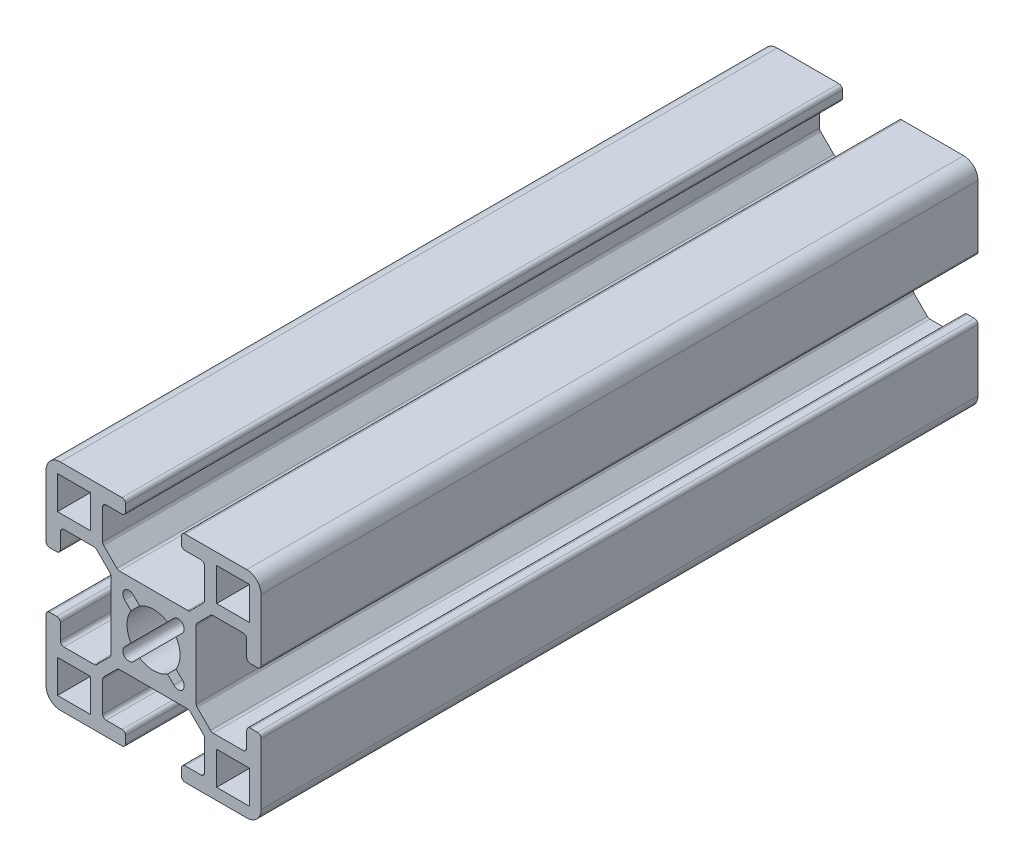
from build123d import *

# Parameters (mm, degrees)
SKETCH1_W           = 4.6
SKETCH1_H           = 4.6
BOSS_EXTRUDE1_DEPTH = 50


with BuildPart() as part:
    # Sketch1 → Boss-Extrude1 (new body, symmetric)
    with BuildSketch(Plane.XY):
        with BuildLine():
            Line((15, -13), (15, -4.4))
            ThreePointArc((15, -4.4), (14.853553391, -4.046446609), (14.5, -3.9))
            Line((14.5, -3.9), (13.5, -3.9))
            ThreePointArc((13.5, -3.9), (13.146446609, -4.046446609), (13, -4.4))
            Line((13, -4.4), (13, -6.6))
            ThreePointArc((13, -6.6), (12.853553391, -6.953553391), (12.5, -7.1))
            Line((12.5, -7.1), (8.297056275, -7.1))
            ThreePointArc((8.297056275, -7.1), (8.105714559, -7.061939766), (7.943502884, -6.953553391))
            Line((7.943502884, -6.953553391), (6.096446609, -5.106497116))
            ThreePointArc((6.096446609, -5.106497116), (5.988060234, -4.944285441), (5.95, -4.752943725))
            Line((5.95, -4.752943725), (5.95, 4.752943725))
            ThreePointArc((5.95, 4.752943725), (5.988060234, 4.944285441), (6.096446609, 5.106497116))
            Line((6.096446609, 5.106497116), (7.943502884, 6.953553391))
            ThreePointArc((7.943502884, 6.953553391), (8.105714559, 7.061939766), (8.297056275, 7.1))
            Line((8.297056275, 7.1), (12.5, 7.1))
            ThreePointArc((12.5, 7.1), (12.853553391, 6.953553391), (13, 6.6))
            Line((13, 6.6), (13, 4.4))
            ThreePointArc((13, 4.4), (13.146446609, 4.046446609), (13.5, 3.9))
            Line((13.5, 3.9), (14.5, 3.9))
            ThreePointArc((14.5, 3.9), (14.853553391, 4.046446609), (15, 4.4))
            Line((15, 4.4), (15, 13))
            ThreePointArc((15, 13), (14.414213562, 14.414213562), (13, 15))
            Line((13, 15), (4.4, 15))
            ThreePointArc((4.4, 15), (4.046446609, 14.853553391), (3.9, 14.5))
            Line((3.9, 14.5), (3.9, 13.5))
            ThreePointArc((3.9, 13.5), (4.046446609, 13.146446609), (4.4, 13))
            Line((4.4, 13), (6.6, 13))
            ThreePointArc((6.6, 13), (6.953553391, 12.853553391), (7.1, 12.5))
            Line((7.1, 12.5), (7.1, 8.297056275))
            ThreePointArc((7.1, 8.297056275), (7.061939766, 8.105714559), (6.953553391, 7.943502884))
            Line((6.953553391, 7.943502884), (5.106497116, 6.096446609))
            ThreePointArc((5.106497116, 6.096446609), (4.944285441, 5.988060234), (4.752943725, 5.95))
            Line((4.752943725, 5.95), (-4.752943725, 5.95))
            ThreePointArc((-4.752943725, 5.95), (-4.944285441, 5.988060234), (-5.106497116, 6.096446609))
            Line((-5.106497116, 6.096446609), (-6.953553391, 7.943502884))
            ThreePointArc((-6.953553391, 7.943502884), (-7.061939766, 8.105714559), (-7.1, 8.297056275))
            Line((-7.1, 8.297056275), (-7.1, 12.5))
            ThreePointArc((-7.1, 12.5), (-6.953553391, 12.853553391), (-6.6, 13))
            Line((-6.6, 13), (-4.4, 13))
            ThreePointArc((-4.4, 13), (-4.046446609, 13.146446609), (-3.9, 13.5))
            Line((-3.9, 13.5), (-3.9, 14.5))
            ThreePointArc((-3.9, 14.5), (-4.046446609, 14.853553391), (-4.4, 15))
            Line((-4.4, 15), (-13, 15))
            ThreePointArc((-13, 15), (-14.414213562, 14.414213562), (-15, 13))
            Line((-15, 13), (-15, 4.4))
            ThreePointArc((-15, 4.4), (-14.853553391, 4.046446609), (-14.5, 3.9))
            Line((-14.5, 3.9), (-13.5, 3.9))
            ThreePointArc((-13.5, 3.9), (-13.146446609, 4.046446609), (-13, 4.4))
            Line((-13, 4.4), (-13, 6.6))
            ThreePointArc((-13, 6.6), (-12.853553391, 6.953553391), (-12.5, 7.1))
            Line((-12.5, 7.1), (-8.297056275, 7.1))
            ThreePointArc((-8.297056275, 7.1), (-8.105714559, 7.061939766), (-7.943502884, 6.953553391))
            Line((-7.943502884, 6.953553391), (-6.096446609, 5.106497116))
            ThreePointArc((-6.096446609, 5.106497116), (-5.988060234, 4.944285441), (-5.95, 4.752943725))
            Line((-5.95, 4.752943725), (-5.95, -4.752943725))
            ThreePointArc((-5.95, -4.752943725), (-5.988060234, -4.944285441), (-6.096446609, -5.106497116))
            Line((-6.096446609, -5.106497116), (-7.943502884, -6.953553391))
            ThreePointArc((-7.943502884, -6.953553391), (-8.105714559, -7.061939766), (-8.297056275, -7.1))
            Line((-8.297056275, -7.1), (-12.5, -7.1))
            ThreePointArc((-12.5, -7.1), (-12.853553391, -6.953553391), (-13, -6.6))
            Line((-13, -6.6), (-13, -4.4))
            ThreePointArc((-13, -4.4), (-13.146446609, -4.046446609), (-13.5, -3.9))
            Line((-13.5, -3.9), (-14.5, -3.9))
            ThreePointArc((-14.5, -3.9), (-14.853553391, -4.046446609), (-15, -4.4))
            Line((-15, -4.4), (-15, -13))
            ThreePointArc((-15, -13), (-14.414213562, -14.414213562), (-13, -15))
            Line((-13, -15), (-4.4, -15))
            ThreePointArc((-4.4, -15), (-4.046446609, -14.853553391), (-3.9, -14.5))
            Line((-3.9, -14.5), (-3.9, -13.5))
            ThreePointArc((-3.9, -13.5), (-4.046446609, -13.146446609), (-4.4, -13))
            Line((-4.4, -13), (-6.6, -13))
            ThreePointArc((-6.6, -13), (-6.953553391, -12.853553391), (-7.1, -12.5))
            Line((-7.1, -12.5), (-7.1, -8.297056275))
            ThreePointArc((-7.1, -8.297056275), (-7.061939766, -8.105714559), (-6.953553391, -7.943502884))
            Line((-6.953553391, -7.943502884), (-5.106497116, -6.096446609))
            ThreePointArc((-5.106497116, -6.096446609), (-4.944285441, -5.988060234), (-4.752943725, -5.95))
            Line((-4.752943725, -5.95), (4.752943725, -5.95))
            ThreePointArc((4.752943725, -5.95), (4.944285441, -5.988060234), (5.106497116, -6.096446609))
            Line((5.106497116, -6.096446609), (6.953553391, -7.943502884))
            ThreePointArc((6.953553391, -7.943502884), (7.061939766, -8.105714559), (7.1, -8.297056275))
            Line((7.1, -8.297056275), (7.1, -12.5))
            ThreePointArc((7.1, -12.5), (6.953553391, -12.853553391), (6.6, -13))
            Line((6.6, -13), (4.4, -13))
            ThreePointArc((4.4, -13), (4.046446609, -13.146446609), (3.9, -13.5))
            Line((3.9, -13.5), (3.9, -14.5))
            ThreePointArc((3.9, -14.5), (4.046446609, -14.853553391), (4.4, -15))
            Line((4.4, -15), (13, -15))
            ThreePointArc((13, -15), (14.414213562, -14.414213562), (15, -13))
        make_face()
        with Locations((-11.1, -11.1)):
            Rectangle(SKETCH1_W, SKETCH1_H, mode=Mode.SUBTRACT)
        with Locations((11.1, -11.1)):
            Rectangle(SKETCH1_W, SKETCH1_H, mode=Mode.SUBTRACT)
        with Locations((11.1, 11.1)):
            Rectangle(SKETCH1_W, SKETCH1_H, mode=Mode.SUBTRACT)
        with BuildLine():
            Line((4.030508653, -2.828427125), (3.147361639, -1.945280111))
            ThreePointArc((3.147361639, -1.945280111), (3.7, 0), (3.147361639, 1.945280111))
            Line((3.147361639, 1.945280111), (4.030508653, 2.828427125))
            ThreePointArc((4.030508653, 2.828427125), (4.030508653, 4.030508653), (2.828427125, 4.030508653))
            Line((2.828427125, 4.030508653), (1.945280111, 3.147361639))
            ThreePointArc((1.945280111, 3.147361639), (0, 3.7), (-1.945280111, 3.147361639))
            Line((-1.945280111, 3.147361639), (-2.828427125, 4.030508653))
            ThreePointArc((-2.828427125, 4.030508653), (-4.030508653, 4.030508653), (-4.030508653, 2.828427125))
            Line((-4.030508653, 2.828427125), (-3.147361639, 1.945280111))
            ThreePointArc((-3.147361639, 1.945280111), (-3.7, 0), (-3.147361639, -1.945280111))
            Line((-3.147361639, -1.945280111), (-4.030508653, -2.828427125))
            ThreePointArc((-4.030508653, -2.828427125), (-4.030508653, -4.030508653), (-2.828427125, -4.030508653))
            Line((-2.828427125, -4.030508653), (-1.945280111, -3.147361639))
            ThreePointArc((-1.945280111, -3.147361639), (0, -3.7), (1.945280111, -3.147361639))
            Line((1.945280111, -3.147361639), (2.828427125, -4.030508653))
            ThreePointArc((2.828427125, -4.030508653), (4.030508653, -4.030508653), (4.030508653, -2.828427125))
        make_face(mode=Mode.SUBTRACT)
        with Locations((-11.1, 11.1)):
            Rectangle(SKETCH1_W, SKETCH1_H, mode=Mode.SUBTRACT)
    extrude(amount=BOSS_EXTRUDE1_DEPTH, both=True)


solid = part.part
